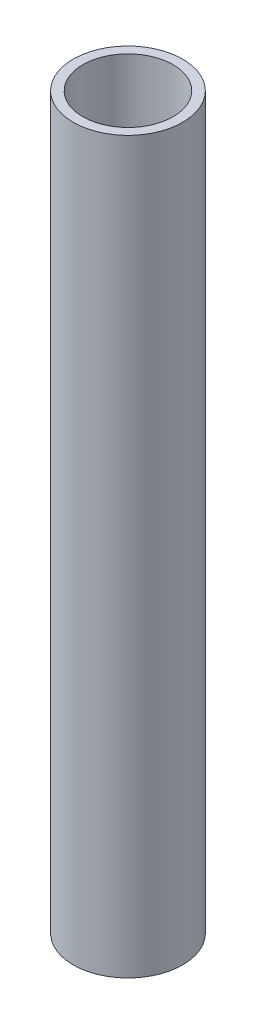
from build123d import *

# Parameters (mm, degrees)
ESQUISSE1_R        = 2.85
ESQUISSE1_R_2      = 2.35
BOSS_EXTRU_1_DEPTH = 38


with BuildPart() as part:
    # Esquisse1 → Boss.-Extru.1 (new body)
    with BuildSketch(Plane(origin=(0, 0, 0), x_dir=(1, 0, 0), z_dir=(0, 1, 0))):
        Circle(ESQUISSE1_R)
        Circle(ESQUISSE1_R_2, mode=Mode.SUBTRACT)
    extrude(amount=BOSS_EXTRU_1_DEPTH)


solid = part.part
